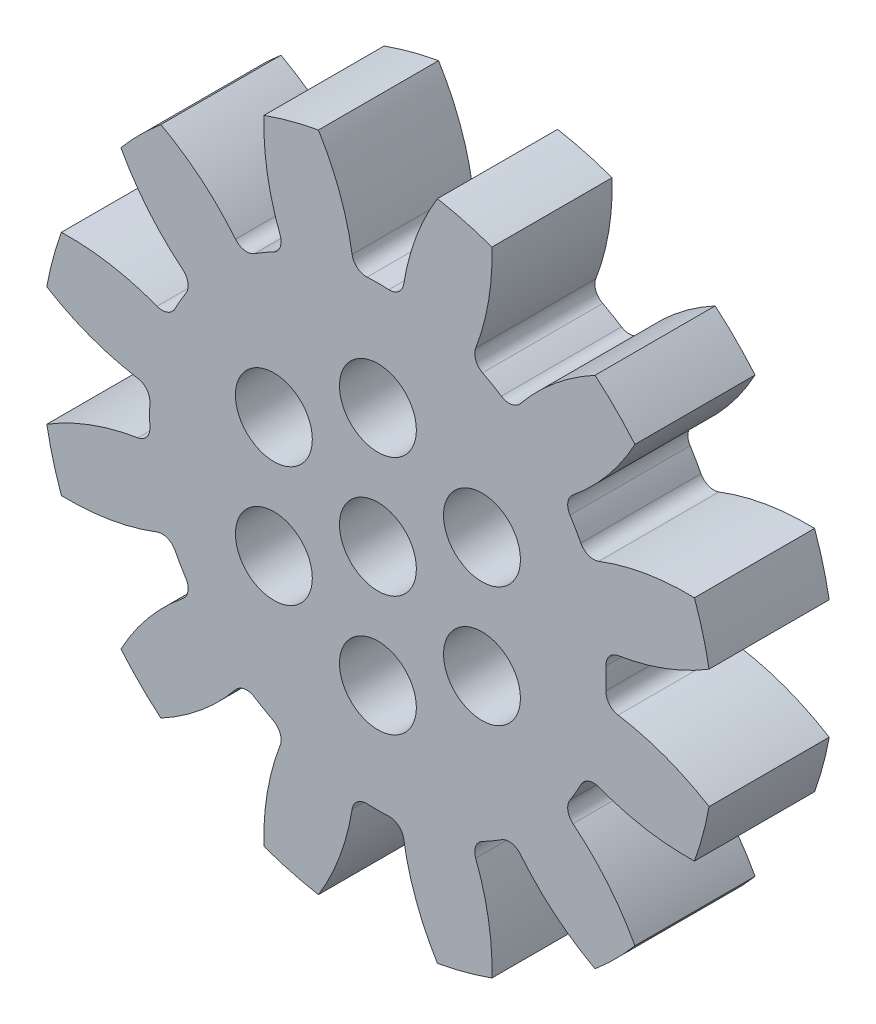
from build123d import *

# Parameters (mm, degrees)
SKETCH1_R                = 14
BOSS_EXTRUDE1_DEPTH      = 2.5
CUT_EXTRUDE1_DEPTH       = 3.5
FILLET1_R                = 0.6
FILLET2_R                = 0.6
CIRPATTERN2_COUNT        = 12
FILLET1_OF_CIRPATTERN2_R = 0.6
FILLET2_OF_CIRPATTERN2_R = 0.6
SKETCH4_R                = 1.5
CUT_EXTRUDE2_DEPTH       = 1.0000001
CUT_EXTRUDE2_DEPTH_BACK  = 6.0000001
SKETCH5_R                = 1.6
CUT_EXTRUDE3_DEPTH       = 6.0000001


with BuildPart() as part:
    # Sketch1 → Boss-Extrude1 (new body, symmetric)
    with BuildSketch(Plane.XY):
        Circle(SKETCH1_R)
    extrude(amount=BOSS_EXTRUDE1_DEPTH, both=True)

    # Sketch2 → Cut-Extrude1 (cut, symmetric)
    with BuildSketch(Plane.XY):
        with BuildLine():
            ThreePointArc((-3.314591405, 14.951229823), (-1.751535203, 12.36983933), (-0.999747632, 9.447248524))
            ThreePointArc((-0.999747632, 9.447248524), (0, 9.5), (0.999747632, 9.447248524))
            ThreePointArc((0.999747632, 9.447248524), (1.751535203, 12.36983933), (3.314591405, 14.951229823))
            ThreePointArc((3.314591405, 14.951229823), (0, 15.314234862), (-3.314591405, 14.951229823))
        make_face()
    cut_extrude1 = extrude(amount=CUT_EXTRUDE1_DEPTH, both=True, mode=Mode.SUBTRACT)

    # Fillet1
    fillet1_edges = [part.edges().sort_by_distance(p)[0] for p in [
        (-0.999747632, 9.447248524, 0),
    ]]
    fillet(fillet1_edges, radius=FILLET1_R)

    # Fillet2
    fillet2_edges = [part.edges().sort_by_distance(p)[0] for p in [
        (0.999747632, 9.447248524, 0),
    ]]
    fillet(fillet2_edges, radius=FILLET2_R)

    # CirPattern2: Cut-Extrude1 ×12 about axis
    cirpattern2_axis = Axis((0, 0, 0), (0, 0, 1))
    for i in range(1, CIRPATTERN2_COUNT):
        add(cut_extrude1.rotate(cirpattern2_axis, i * 360 / CIRPATTERN2_COUNT), mode=Mode.SUBTRACT)

    # Fillet1 of CirPattern2
    fillet1_of_cirpattern2_edges = [part.edges().sort_by_distance(p)[0] for p in [
        (-5.589431109, 7.681683401, 0),
        (-8.681431034, 3.857817415, 0),
        (-9.447248524, -0.999747632, 0),
        (-7.681683401, -5.589431109, 0),
        (-3.857817415, -8.681431034, 0),
        (0.999747632, -9.447248524, 0),
        (5.589431109, -7.681683401, 0),
        (8.681431034, -3.857817415, 0),
        (9.447248524, 0.999747632, 0),
        (7.681683401, 5.589431109, 0),
        (3.857817415, 8.681431034, 0),
    ]]
    fillet(fillet1_of_cirpattern2_edges, radius=FILLET1_OF_CIRPATTERN2_R)

    # Fillet2 of CirPattern2
    fillet2_of_cirpattern2_edges = [part.edges().sort_by_distance(p)[0] for p in [
        (-3.857817415, 8.681431034, 0),
        (-7.681683401, 5.589431109, 0),
        (-9.447248524, 0.999747632, 0),
        (-8.681431034, -3.857817415, 0),
        (-5.589431109, -7.681683401, 0),
        (-0.999747632, -9.447248524, 0),
        (3.857817415, -8.681431034, 0),
        (7.681683401, -5.589431109, 0),
        (9.447248524, -0.999747632, 0),
        (8.681431034, 3.857817415, 0),
        (5.589431109, 7.681683401, 0),
    ]]
    fillet(fillet2_of_cirpattern2_edges, radius=FILLET2_OF_CIRPATTERN2_R)

    # Sketch4 → Cut-Extrude2 (cut, two sides)
    with BuildSketch(Plane.XY.offset(2.5)) as cut_extrude2_sk:
        Circle(SKETCH4_R)
        with Locations((0, 5)):
            Circle(SKETCH4_R)
        with Locations((4.330127019, 2.5)):
            Circle(SKETCH4_R)
        with Locations((4.330127019, -2.5)):
            Circle(SKETCH4_R)
        with Locations((0, -5)):
            Circle(SKETCH4_R)
        with Locations((-4.330127019, -2.5)):
            Circle(SKETCH4_R)
        with Locations((-4.330127019, 2.5)):
            Circle(SKETCH4_R)
    extrude(amount=CUT_EXTRUDE2_DEPTH, mode=Mode.SUBTRACT)
    extrude(cut_extrude2_sk.sketch, amount=-CUT_EXTRUDE2_DEPTH_BACK, mode=Mode.SUBTRACT)

    # Sketch5 → Cut-Extrude3 (cut, through all)
    with BuildSketch(Plane.XY.offset(2.5)):
        with Locations((0, 5)):
            Circle(SKETCH5_R)
        with Locations((4.330127019, 2.5)):
            Circle(SKETCH5_R)
        with Locations((4.330127019, -2.5)):
            Circle(SKETCH5_R)
        with Locations((0, -5)):
            Circle(SKETCH5_R)
        Circle(SKETCH5_R)
        with Locations((-4.330127019, -2.5)):
            Circle(SKETCH5_R)
        with Locations((-4.330127019, 2.5)):
            Circle(SKETCH5_R)
    extrude(amount=-CUT_EXTRUDE3_DEPTH, mode=Mode.SUBTRACT)


solid = part.part
